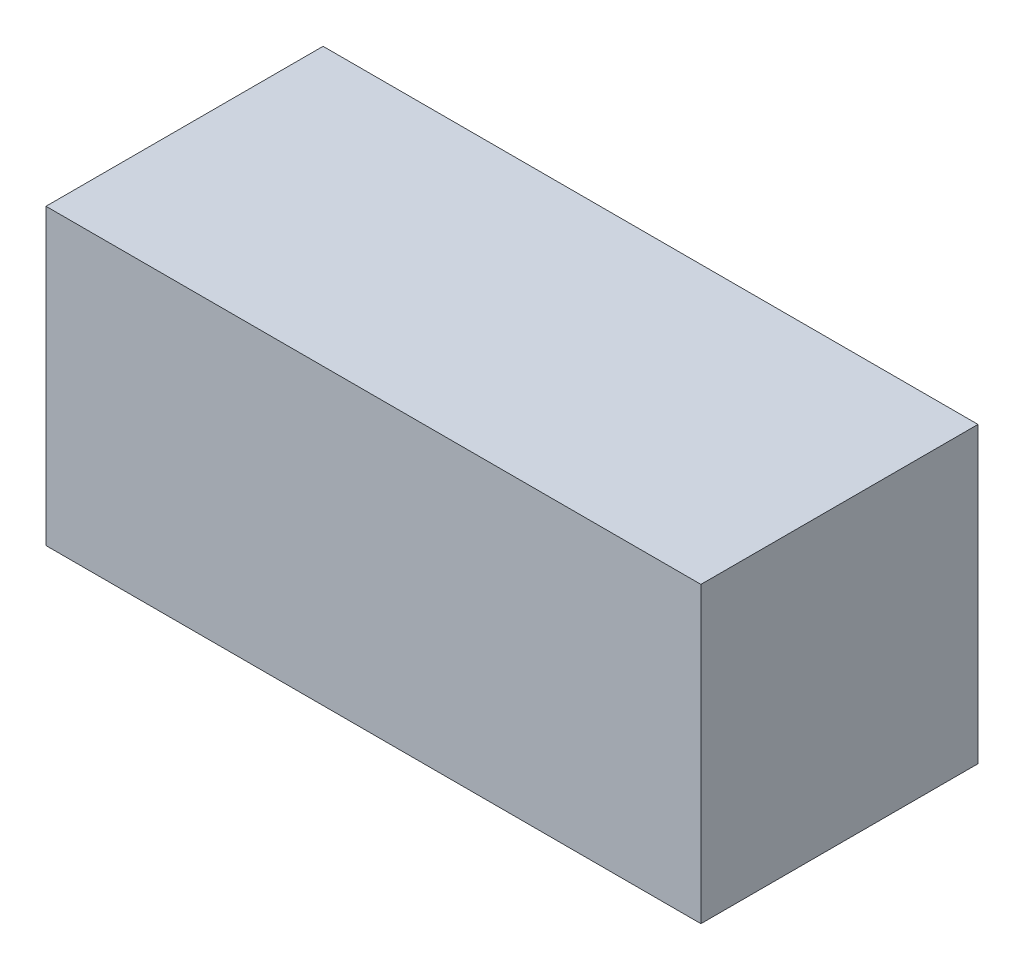
from build123d import *

# Parameters (mm, degrees)
ESQUISSE1_W        = 78
ESQUISSE1_H        = 35
BOSS_EXTRU_1_DEPTH = 33


with BuildPart() as part:
    # Esquisse1 → Boss.-Extru.1 (new body)
    with BuildSketch(Plane.XY):
        with Locations((39, 17.5)):
            Rectangle(ESQUISSE1_W, ESQUISSE1_H)
    extrude(amount=BOSS_EXTRU_1_DEPTH)


solid = part.part
